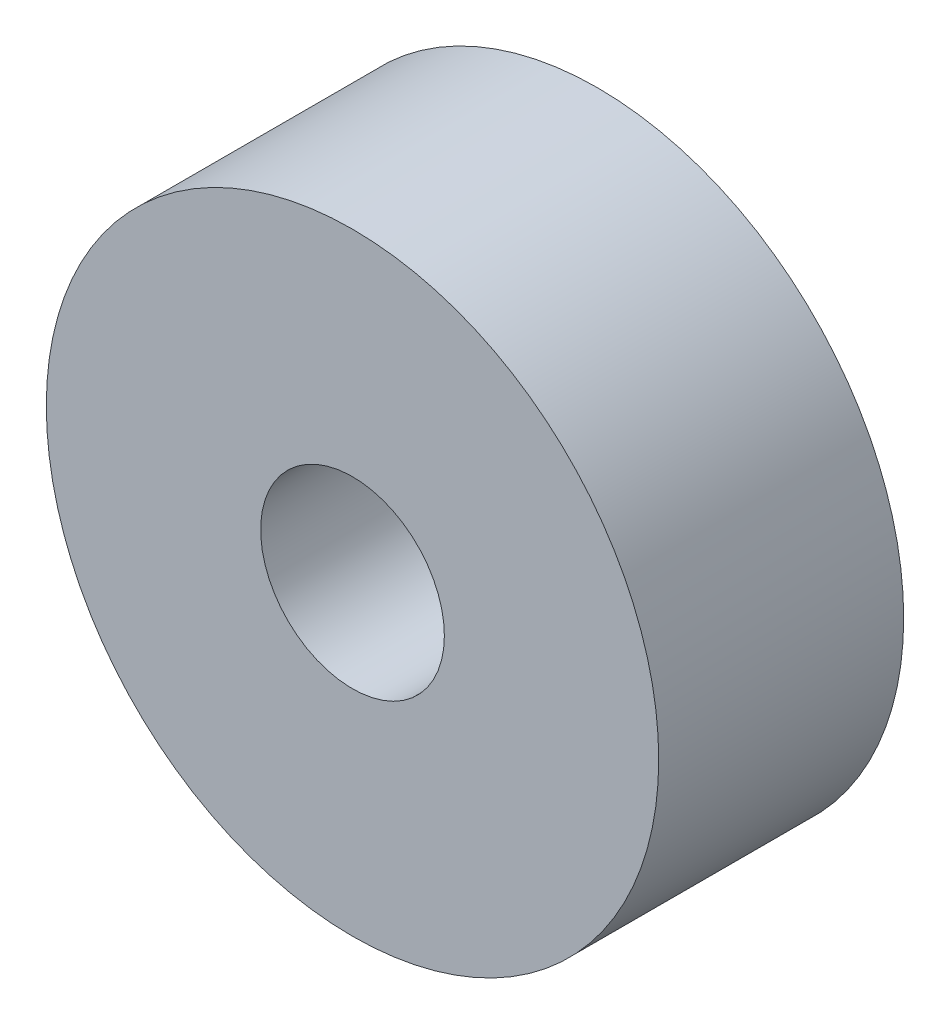
from build123d import *

# Parameters (mm, degrees)
ESQUISSE1_R        = 5
ESQUISSE1_R_2      = 1.5
BOSS_EXTRU_1_DEPTH = 4


with BuildPart() as part:
    # Esquisse1 → Boss.-Extru.1 (new body)
    with BuildSketch(Plane.XY):
        Circle(ESQUISSE1_R)
        Circle(ESQUISSE1_R_2, mode=Mode.SUBTRACT)
    extrude(amount=BOSS_EXTRU_1_DEPTH)


solid = part.part
